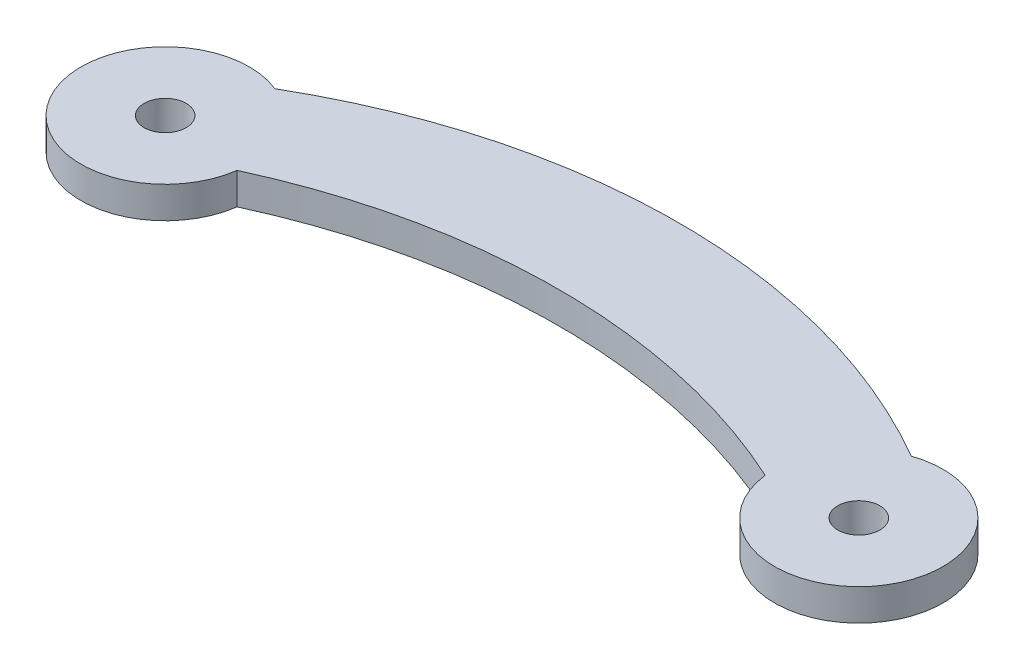
from build123d import *

# Parameters (mm, degrees)
BOSS_EXTRUDE1_DEPTH = 1.5
SKETCH3_R           = 1
CUT_EXTRUDE1_DEPTH  = 11.5


with BuildPart() as part:
    # Sketch1 → Boss-Extrude1 (new body)
    with BuildSketch(Plane(origin=(0, 0, 0), x_dir=(1, 0, 0), z_dir=(0, 1, 0))):
        with BuildLine():
            ThreePointArc((1.506452417, 3.705482575), (-3.464101615, -2), (3.962268252, -0.548115225))
            ThreePointArc((3.962268252, -0.548115225), (16.494990723, 2.195126577), (29.027713195, -0.548115225))
            ThreePointArc((29.027713195, -0.548115225), (36.386316352, -2.207127095), (31.702043975, 3.705482575))
            ThreePointArc((31.702043975, 3.705482575), (16.604248196, 7.78142883), (1.506452417, 3.705482575))
        make_face()
    extrude(amount=BOSS_EXTRUDE1_DEPTH)

    # Sketch3 → Cut-Extrude1 (cut)
    with BuildSketch(Plane(origin=(0, 1.5, 0), x_dir=(1, 0, 0), z_dir=(0, 1, 0))):
        with Locations((33, -0.078075295)):
            Circle(SKETCH3_R)
        Circle(SKETCH3_R)
    extrude(amount=-CUT_EXTRUDE1_DEPTH, mode=Mode.SUBTRACT)


solid = part.part
